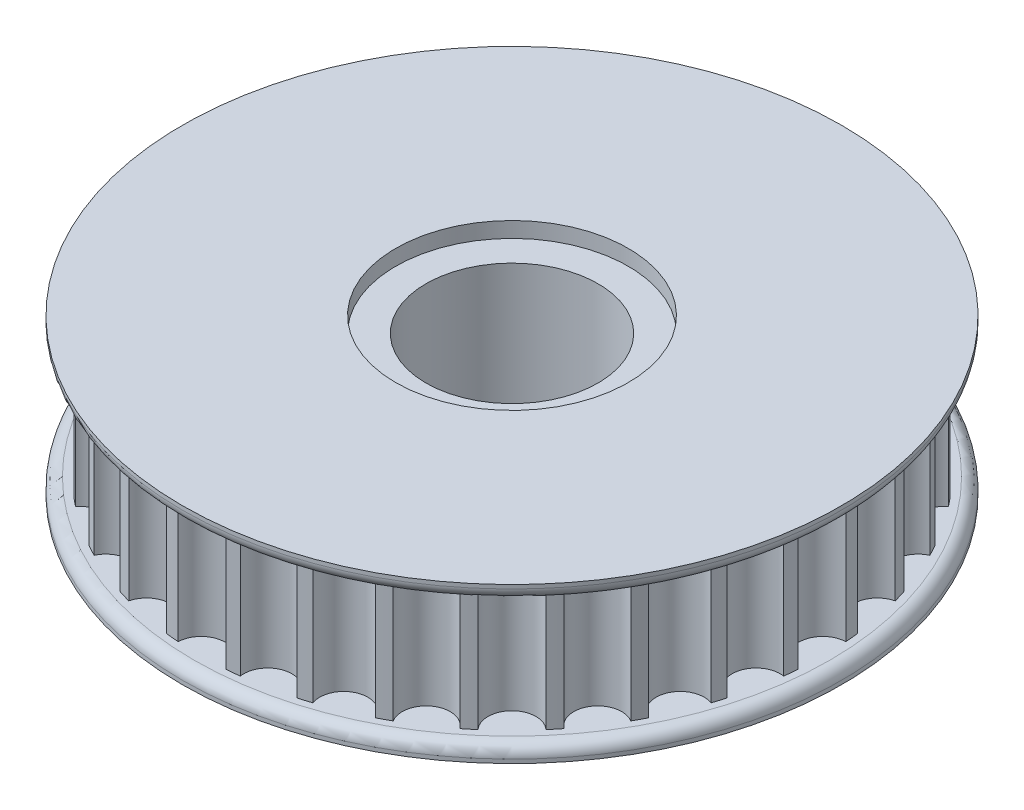
from build123d import *

# Parameters (mm, degrees)
SKETCH1_R           = 11.1
BOSS_EXTRUDE1_DEPTH = 8
SKETCH2_R           = 42.5
SKETCH2_R_2         = 15
BOSS_EXTRUDE2_DEPTH = 2
FILLET1_R           = 1.5


with BuildPart() as part:
    # Sketch1 → Boss-Extrude1 (new body, symmetric)
    with BuildSketch(Plane(origin=(0, 0, 0), x_dir=(1, 0, 0), z_dir=(0, 1, 0))):
        with BuildLine():
            ThreePointArc((39.96011477, -3.097680993), (36.98, 0), (39.96011477, 3.097680993))
            ThreePointArc((39.96011477, 3.097680993), (39.887003845, 3.928526984), (39.796619952, 4.757671737))
            ThreePointArc((39.796619952, 4.757671737), (36.269439669, 7.214440108), (38.587964788, 10.833991579))
            ThreePointArc((38.587964788, 10.833991579), (38.354168656, 11.634609864), (38.103763348, 12.430189811))
            ThreePointArc((38.103763348, 12.430189811), (34.165065112, 14.151633329), (35.732900959, 18.153957945))
            ThreePointArc((35.732900959, 18.153957945), (35.347404275, 18.893581212), (34.946600487, 19.625022661))
            ThreePointArc((34.946600487, 19.625022661), (30.747746263, 20.544987217), (31.504641785, 24.776277888))
            ThreePointArc((31.504641785, 24.776277888), (30.982258971, 25.426482829), (30.446459367, 26.065676895))
            ThreePointArc((30.446459367, 26.065676895), (26.148808768, 26.148808768), (26.065676895, 30.446459367))
            ThreePointArc((26.065676895, 30.446459367), (25.426482829, 30.982258971), (24.776277888, 31.504641785))
            ThreePointArc((24.776277888, 31.504641785), (20.544987217, 30.747746263), (19.625022661, 34.946600487))
            ThreePointArc((19.625022661, 34.946600487), (18.893581212, 35.347404275), (18.153957945, 35.732900959))
            ThreePointArc((18.153957945, 35.732900959), (14.151633329, 34.165065112), (12.430189811, 38.103763348))
            ThreePointArc((12.430189811, 38.103763348), (11.634609864, 38.354168656), (10.833991579, 38.587964788))
            ThreePointArc((10.833991579, 38.587964788), (7.214440108, 36.269439669), (4.757671737, 39.796619952))
            ThreePointArc((4.757671737, 39.796619952), (3.928526984, 39.887003845), (3.097680993, 39.96011477))
            ThreePointArc((3.097680993, 39.96011477), (0, 36.98), (-3.097680993, 39.96011477))
            ThreePointArc((-3.097680993, 39.96011477), (-3.928526984, 39.887003845), (-4.757671737, 39.796619952))
            ThreePointArc((-4.757671737, 39.796619952), (-7.214440108, 36.269439669), (-10.833991579, 38.587964788))
            ThreePointArc((-10.833991579, 38.587964788), (-11.634609864, 38.354168656), (-12.430189811, 38.103763348))
            ThreePointArc((-12.430189811, 38.103763348), (-14.151633329, 34.165065112), (-18.153957945, 35.732900959))
            ThreePointArc((-18.153957945, 35.732900959), (-18.893581212, 35.347404275), (-19.625022661, 34.946600487))
            ThreePointArc((-19.625022661, 34.946600487), (-20.544987217, 30.747746263), (-24.776277888, 31.504641785))
            ThreePointArc((-24.776277888, 31.504641785), (-25.426482829, 30.982258971), (-26.065676895, 30.446459367))
            ThreePointArc((-26.065676895, 30.446459367), (-26.148808768, 26.148808768), (-30.446459367, 26.065676895))
            ThreePointArc((-30.446459367, 26.065676895), (-30.982258971, 25.426482829), (-31.504641785, 24.776277888))
            ThreePointArc((-31.504641785, 24.776277888), (-30.747746263, 20.544987217), (-34.946600487, 19.625022661))
            ThreePointArc((-34.946600487, 19.625022661), (-35.347404275, 18.893581212), (-35.732900959, 18.153957945))
            ThreePointArc((-35.732900959, 18.153957945), (-34.165065112, 14.151633329), (-38.103763348, 12.430189811))
            ThreePointArc((-38.103763348, 12.430189811), (-38.354168656, 11.634609864), (-38.587964788, 10.833991579))
            ThreePointArc((-38.587964788, 10.833991579), (-36.269439669, 7.214440108), (-39.796619952, 4.757671737))
            ThreePointArc((-39.796619952, 4.757671737), (-39.887003845, 3.928526984), (-39.96011477, 3.097680993))
            ThreePointArc((-39.96011477, 3.097680993), (-36.98, 0), (-39.96011477, -3.097680993))
            ThreePointArc((-39.96011477, -3.097680993), (-39.887003845, -3.928526984), (-39.796619952, -4.757671737))
            ThreePointArc((-39.796619952, -4.757671737), (-36.269439669, -7.214440108), (-38.587964788, -10.833991579))
            ThreePointArc((-38.587964788, -10.833991579), (-38.354168656, -11.634609864), (-38.103763348, -12.430189811))
            ThreePointArc((-38.103763348, -12.430189811), (-34.165065112, -14.151633329), (-35.732900959, -18.153957945))
            ThreePointArc((-35.732900959, -18.153957945), (-35.347404275, -18.893581212), (-34.946600487, -19.625022661))
            ThreePointArc((-34.946600487, -19.625022661), (-30.747746263, -20.544987217), (-31.504641785, -24.776277888))
            ThreePointArc((-31.504641785, -24.776277888), (-30.982258971, -25.426482829), (-30.446459367, -26.065676895))
            ThreePointArc((-30.446459367, -26.065676895), (-26.148808768, -26.148808768), (-26.065676895, -30.446459367))
            ThreePointArc((-26.065676895, -30.446459367), (-25.426482829, -30.982258971), (-24.776277888, -31.504641785))
            ThreePointArc((-24.776277888, -31.504641785), (-20.544987217, -30.747746263), (-19.625022661, -34.946600487))
            ThreePointArc((-19.625022661, -34.946600487), (-18.893581212, -35.347404275), (-18.153957945, -35.732900959))
            ThreePointArc((-18.153957945, -35.732900959), (-14.151633329, -34.165065112), (-12.430189811, -38.103763348))
            ThreePointArc((-12.430189811, -38.103763348), (-11.634609864, -38.354168656), (-10.833991579, -38.587964788))
            ThreePointArc((-10.833991579, -38.587964788), (-7.214440108, -36.269439669), (-4.757671737, -39.796619952))
            ThreePointArc((-4.757671737, -39.796619952), (-3.928526984, -39.887003845), (-3.097680993, -39.96011477))
            ThreePointArc((-3.097680993, -39.96011477), (0, -36.98), (3.097680993, -39.96011477))
            ThreePointArc((3.097680993, -39.96011477), (3.928526984, -39.887003845), (4.757671737, -39.796619952))
            ThreePointArc((4.757671737, -39.796619952), (7.214440108, -36.269439669), (10.833991579, -38.587964788))
            ThreePointArc((10.833991579, -38.587964788), (11.634609864, -38.354168656), (12.430189811, -38.103763348))
            ThreePointArc((12.430189811, -38.103763348), (14.151633329, -34.165065112), (18.153957945, -35.732900959))
            ThreePointArc((18.153957945, -35.732900959), (18.893581212, -35.347404275), (19.625022661, -34.946600487))
            ThreePointArc((19.625022661, -34.946600487), (20.544987217, -30.747746263), (24.776277888, -31.504641785))
            ThreePointArc((24.776277888, -31.504641785), (25.426482829, -30.982258971), (26.065676895, -30.446459367))
            ThreePointArc((26.065676895, -30.446459367), (26.148808768, -26.148808768), (30.446459367, -26.065676895))
            ThreePointArc((30.446459367, -26.065676895), (30.982258971, -25.426482829), (31.504641785, -24.776277888))
            ThreePointArc((31.504641785, -24.776277888), (30.747746263, -20.544987217), (34.946600487, -19.625022661))
            ThreePointArc((34.946600487, -19.625022661), (35.347404275, -18.893581212), (35.732900959, -18.153957945))
            ThreePointArc((35.732900959, -18.153957945), (34.165065112, -14.151633329), (38.103763348, -12.430189811))
            ThreePointArc((38.103763348, -12.430189811), (38.354168656, -11.634609864), (38.587964788, -10.833991579))
            ThreePointArc((38.587964788, -10.833991579), (36.269439669, -7.214440108), (39.796619952, -4.757671737))
            ThreePointArc((39.796619952, -4.757671737), (39.887003845, -3.928526984), (39.96011477, -3.097680993))
        make_face()
        Circle(SKETCH1_R, mode=Mode.SUBTRACT)
    extrude(amount=BOSS_EXTRUDE1_DEPTH, both=True)

    # Sketch2 → Boss-Extrude2 (add)
    with BuildSketch(Plane(origin=(0, 8, 0), x_dir=(1, 0, 0), z_dir=(0, 1, 0))):
        Circle(SKETCH2_R)
        Circle(SKETCH2_R_2, mode=Mode.SUBTRACT)
    boss_extrude2 = extrude(amount=BOSS_EXTRUDE2_DEPTH)

    # Mirror1: Boss-Extrude2 across plane
    add(boss_extrude2.mirror(Plane.ZX))

    # Fillet1
    fillet1_edges = [part.edges().sort_by_distance(p)[0] for p in [
        (-42.5, 8, 0),
        (-42.5, -8, 0),
    ]]
    fillet(fillet1_edges, radius=FILLET1_R)


solid = part.part
